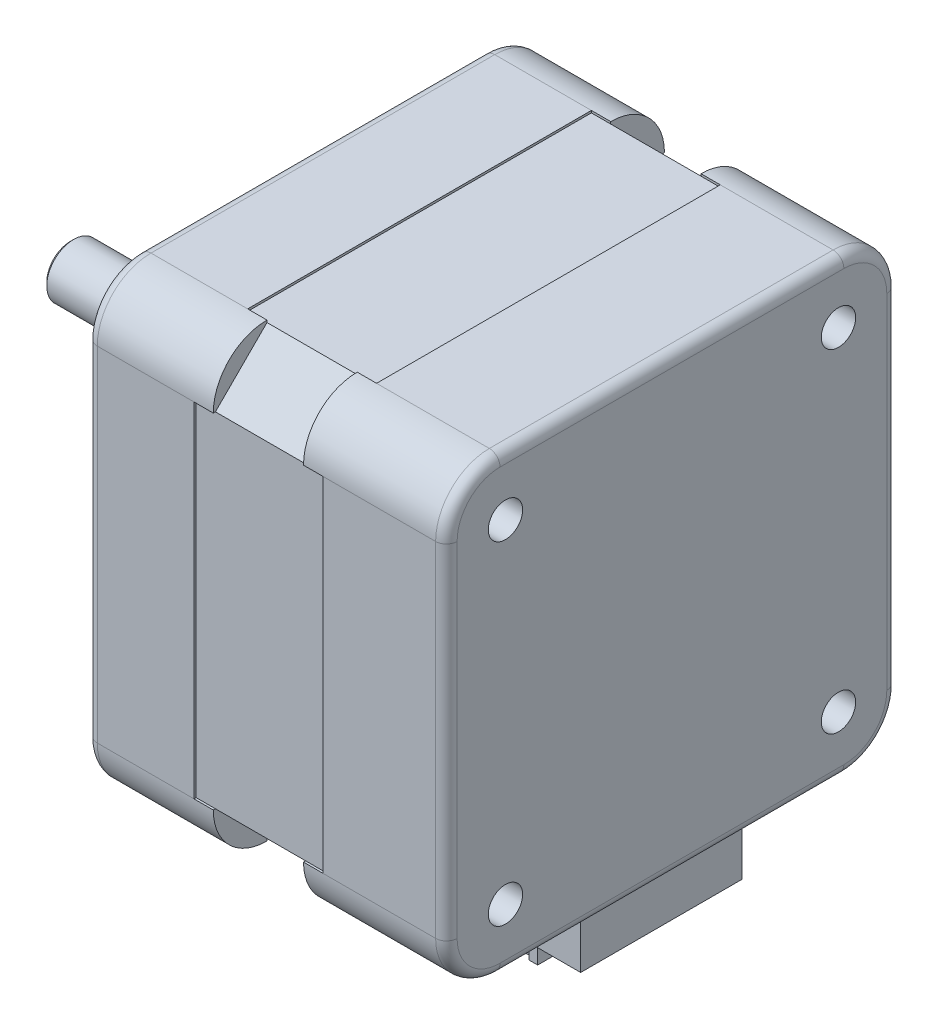
from build123d import *

# Parameters (mm, degrees)
SKETCH1_W           = 42
SKETCH1_H           = 42
BASE_EXTRUDE_DEPTH  = 33.5
FILLET1_R           = 5
SKETCH2_R           = 11
SKETCH2_R_2         = 8
BOSS_EXTRUDE1_DEPTH = 2
SKETCH3_R           = 2.5
BOSS_EXTRUDE2_DEPTH = 22.5
FILLET2_R           = 1
SKETCH4_R           = 1.6
CUT_EXTRUDE1_DEPTH  = 45.768850778
SKETCH5_R           = 1.6
CUT_EXTRUDE2_DEPTH  = 45.768850778
SKETCH6_R           = 1.6
CUT_EXTRUDE3_DEPTH  = 45.768850778
SKETCH7_R           = 1.6
CUT_EXTRUDE4_DEPTH  = 45.768850778
SKETCH9_OUTSIDE_W   = 60.326
SKETCH9_OUTSIDE_H   = 60.326
CUT_EXTRUDE8_DEPTH  = 12
BOSS_EXTRUDE3_START = 1.8
BOSS_EXTRUDE3_DEPTH = 1.8
BOSS_EXTRUDE4_DEPTH = 1.8
CIRPATTERN1_COUNT   = 4
SKETCH13_W          = 4
SKETCH13_H          = 15
BOSS_EXTRUDE6_DEPTH = 4.5
SKETCH14_W          = 5
SKETCH14_H          = 14
BOSS_EXTRUDE7_DEPTH = 6
SKETCH15_W          = 4
SKETCH15_H          = 13
CUT_EXTRUDE9_DEPTH  = 5.7
SKETCH16_W          = 4
SKETCH16_H          = 8
CUT_EXTRUDE10_DEPTH = 1
SKETCH17_W          = 0.5
SKETCH17_H          = 0.5
BOSS_EXTRUDE8_DEPTH = 3.5
LPATTERN1_COUNT     = 6
LPATTERN1_PITCH     = 2
SKETCH18_W          = 0.8
SKETCH18_H          = 14.8
BOSS_EXTRUDE9_DEPTH = 6
CHAMFER1_SIZE       = 0.3


with BuildPart() as part:
    # Sketch1 → Base-Extrude (new body)
    with BuildSketch(Plane(origin=(0, 0, 0), x_dir=(0, 0, 1), z_dir=(1, 0, 0))):
        Rectangle(SKETCH1_W, SKETCH1_H)
    extrude(amount=BASE_EXTRUDE_DEPTH)

    # Fillet1
    fillet1_edges = [part.edges().sort_by_distance(p)[0] for p in [
        (16.75, -21, 21),
        (16.75, -21, -21),
        (16.75, 21, 21),
        (16.75, 21, -21),
    ]]
    fillet(fillet1_edges, radius=FILLET1_R)

    # Sketch2 → Boss-Extrude1 (add)
    with BuildSketch(Plane(origin=(0, 0, 0), x_dir=(0, 1, 0), z_dir=(-1, 0, 0))):
        Circle(SKETCH2_R)
        Circle(SKETCH2_R_2, mode=Mode.SUBTRACT)
    extrude(amount=BOSS_EXTRUDE1_DEPTH)

    # Sketch3 → Boss-Extrude2 (add)
    with BuildSketch(Plane(origin=(0, 0, 0), x_dir=(0, 1, 0), z_dir=(-1, 0, 0))):
        Circle(SKETCH3_R)
    extrude(amount=BOSS_EXTRUDE2_DEPTH)

    # Fillet2
    fillet2_edges = [part.edges().sort_by_distance(p)[0] for p in [
        (0, 21, 0),
        (0, 19.535533906, 19.535533906),
        (0, 0, 21),
        (0, -19.535533906, 19.535533906),
        (0, -21, 0),
        (0, -19.535533906, -19.535533906),
        (0, 0, -21),
        (0, 19.535533906, -19.535533906),
        (33.5, 21, 0),
        (33.5, 19.535533906, 19.535533906),
        (33.5, 0, 21),
        (33.5, -19.535533906, 19.535533906),
        (33.5, -21, 0),
        (33.5, -19.535533906, -19.535533906),
        (33.5, 0, -21),
        (33.5, 19.535533906, -19.535533906),
    ]]
    fillet(fillet2_edges, radius=FILLET2_R)

    # Sketch4 → Cut-Extrude1 (cut, through all)
    with BuildSketch(Plane.ZY):
        with Locations((-15.5, 15.5)):
            Circle(SKETCH4_R)
    extrude(amount=-CUT_EXTRUDE1_DEPTH, mode=Mode.SUBTRACT)

    # Sketch5 → Cut-Extrude2 (cut, through all)
    with BuildSketch(Plane.ZY):
        with Locations((-15.5, -15.5)):
            Circle(SKETCH5_R)
    extrude(amount=-CUT_EXTRUDE2_DEPTH, mode=Mode.SUBTRACT)

    # Sketch6 → Cut-Extrude3 (cut, through all)
    with BuildSketch(Plane(origin=(0, 0, 0), x_dir=(0, 0, -1), z_dir=(-1, 0, 0))):
        with Locations((-15.5, -15.5)):
            Circle(SKETCH6_R)
    extrude(amount=-CUT_EXTRUDE3_DEPTH, mode=Mode.SUBTRACT)

    # Sketch7 → Cut-Extrude4 (cut, through all)
    with BuildSketch(Plane(origin=(0, 0, 0), x_dir=(0, 0, -1), z_dir=(-1, 0, 0))):
        with Locations((-15.5, 15.5)):
            Circle(SKETCH7_R)
    extrude(amount=-CUT_EXTRUDE4_DEPTH, mode=Mode.SUBTRACT)

    # Sketch9 outside → Cut-Extrude8 (cut)
    with BuildSketch(Plane(origin=(10, 0, 0), x_dir=(0, 0, -1), z_dir=(1, 0, 0))):
        Rectangle(SKETCH9_OUTSIDE_W, SKETCH9_OUTSIDE_H)
        Polygon((20.8, 16), (20.8, -16), (16, -20.8), (-16, -20.8), (-20.8, -16), (-20.8, 16), (-16, 20.8), (16, 20.8), align=None, mode=Mode.SUBTRACT)
    extrude(amount=CUT_EXTRUDE8_DEPTH, mode=Mode.SUBTRACT)

    # Sketch10 → Boss-Extrude3 (add)
    with BuildSketch(Plane(origin=(10, 0, 0), x_dir=(0, 0, -1), z_dir=(1, 0, 0)).offset(BOSS_EXTRUDE3_START)):
        with BuildLine():
            Line((-16, 20.8), (-20.8, 16))
            Line((-20.8, 16), (-21, 16))
            ThreePointArc((-21, 16), (-19.535533906, 19.535533906), (-16, 21))
            Line((-16, 21), (-16, 20.8))
        make_face()
    boss_extrude3 = extrude(amount=-BOSS_EXTRUDE3_DEPTH)

    # Sketch11 → Boss-Extrude4 (add)
    with BuildSketch(Plane.ZY.offset(-22)):
        with BuildLine():
            Line((16, 20.8), (20.8, 16))
            Line((20.8, 16), (21, 16))
            ThreePointArc((21, 16), (19.535533906, 19.535533906), (16, 21))
            Line((16, 21), (16, 20.8))
        make_face()
    boss_extrude4 = extrude(amount=BOSS_EXTRUDE4_DEPTH)

    # CirPattern1: Boss-Extrude3, Boss-Extrude4 ×4 about axis
    cirpattern1_axis = Axis((-22.5, 0, 0), (1, 0, 0))
    add([boss_extrude3.rotate(cirpattern1_axis, i * 360 / CIRPATTERN1_COUNT) for i in range(1, CIRPATTERN1_COUNT)])
    add([boss_extrude4.rotate(cirpattern1_axis, i * 360 / CIRPATTERN1_COUNT) for i in range(1, CIRPATTERN1_COUNT)])

    # Sketch13 → Boss-Extrude6 (add)
    with BuildSketch(Plane.XZ.offset(21)):
        with Locations((30.5, 0)):
            Rectangle(SKETCH13_W, SKETCH13_H)
    extrude(amount=BOSS_EXTRUDE6_DEPTH)

    # Sketch14 → Boss-Extrude7 (add)
    with BuildSketch(Plane(origin=(-111.861481215, -21, -36.560355199), x_dir=(1, 0, 0), z_dir=(0, -1, 0))):
        with Locations((136.861481215, 36.560355199)):
            Rectangle(SKETCH14_W, SKETCH14_H)
    extrude(amount=BOSS_EXTRUDE7_DEPTH)

    # Sketch15 → Cut-Extrude9 (cut)
    with BuildSketch(Plane(origin=(-111.861481215, -27, 3.287540826), x_dir=(-1, 0, 0), z_dir=(0, -1, 0))):
        with Locations((-136.861481215, 3.287540826)):
            Rectangle(SKETCH15_W, SKETCH15_H)
    extrude(amount=-CUT_EXTRUDE9_DEPTH, mode=Mode.SUBTRACT)

    # Sketch16 → Cut-Extrude10 (cut)
    with BuildSketch(Plane(origin=(22.5, -161.361481215, -36.560355199), x_dir=(0, 1, 0), z_dir=(1, 0, 0))):
        with Locations((136.361481215, 36.560355199)):
            Rectangle(SKETCH16_W, SKETCH16_H)
    extrude(amount=CUT_EXTRUDE10_DEPTH, mode=Mode.SUBTRACT)

    # Sketch17 → Boss-Extrude8 (add)
    with BuildSketch(Plane(origin=(-20.898451589, -21.3, 138.79747363), x_dir=(0, 0, 1), z_dir=(0, -1, 0))):
        with Locations((-133.79747363, -46.148451589)):
            Rectangle(SKETCH17_W, SKETCH17_H)
    boss_extrude8 = extrude(amount=BOSS_EXTRUDE8_DEPTH)

    # LPattern1: Boss-Extrude8 ×6
    with Locations(*[(0, 0, -i * LPATTERN1_PITCH) for i in range(1, LPATTERN1_COUNT)]):
        add(boss_extrude8)

    # Sketch18 → Boss-Extrude9 (add)
    with BuildSketch(Plane.XZ.offset(21)):
        with Locations((28, 0)):
            Rectangle(SKETCH18_W, SKETCH18_H)
    extrude(amount=BOSS_EXTRUDE9_DEPTH)

    # Chamfer1
    chamfer1_edges = [part.edges().sort_by_distance(p)[0] for p in [
        (-22.5, -2.5, 0),
    ]]
    chamfer(chamfer1_edges, length=CHAMFER1_SIZE)


solid = part.part
